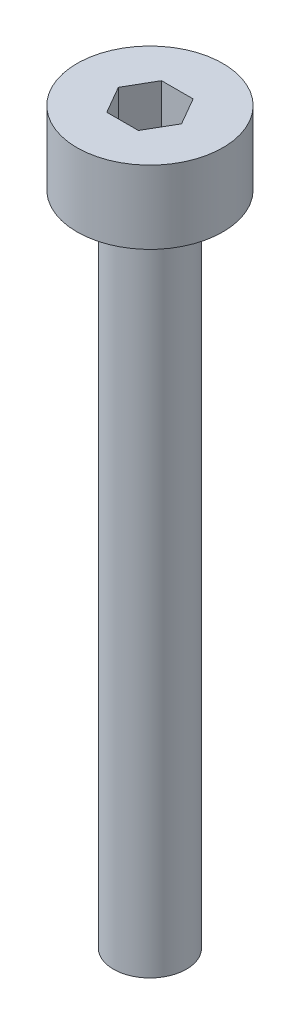
from build123d import *

# Parameters (mm, degrees)
SKETCH_1_R            = 2
EXTRUDE_246_DEPTH     = 2
CUT_EXTRUDE_376_DEPTH = 1.5
SKETCH_3_R            = 1
EXTRUDE_477_DEPTH     = 18


with BuildPart() as part:
    # 草图1 → Extrude 246 (new body)
    with BuildSketch(Plane(origin=(0, 0, 0), x_dir=(1, 0, 0), z_dir=(0, 1, 0))):
        Circle(SKETCH_1_R)
    extrude(amount=EXTRUDE_246_DEPTH)

    # 草图2 → Cut-Extrude 376 (cut)
    with BuildSketch(Plane(origin=(0, 2, 0), x_dir=(1, 0, 0), z_dir=(0, 1, 0))):
        Polygon((0.866025404, 0), (0.433012702, 0.75), (-0.433012702, 0.75), (-0.866025404, 0), (-0.433012702, -0.75), (0.433012702, -0.75), align=None)
    extrude(amount=-CUT_EXTRUDE_376_DEPTH, mode=Mode.SUBTRACT)

    # 草图3 → Extrude 477 (add)
    with BuildSketch(Plane.XZ):
        Circle(SKETCH_3_R)
    extrude(amount=EXTRUDE_477_DEPTH)


solid = part.part
